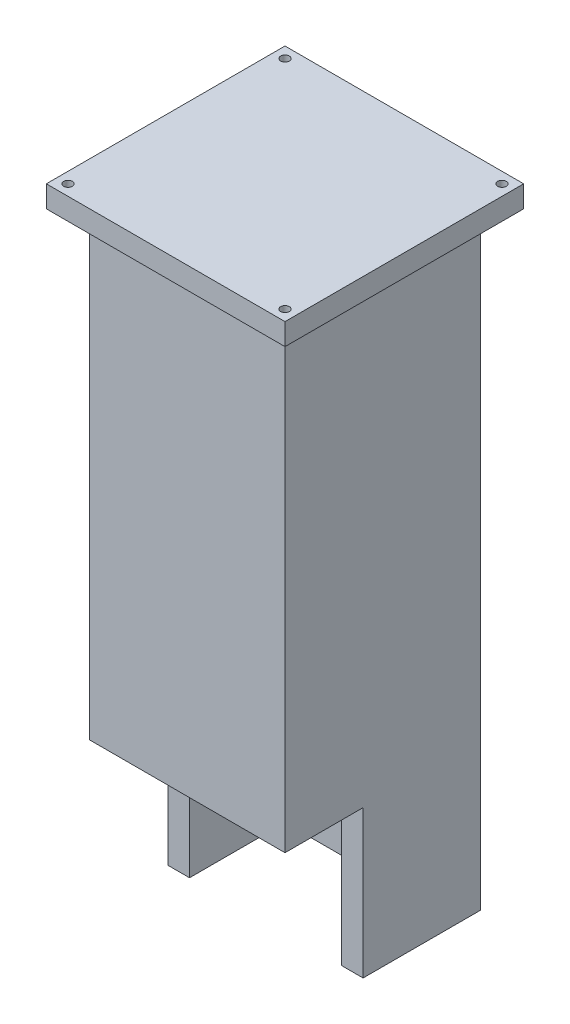
from build123d import *

# Parameters (mm, degrees)
CROQUIS1_W                 = 45
CROQUIS1_H                 = 45
SALIENTE_EXTRUIR1_DEPTH    = 300
CROQUIS4_W                 = 18
CROQUIS4_H                 = 34
CORTAR_EXTRUIR2_DEPTH      = 46
CROQUIS8_W                 = 35
CROQUIS8_H                 = 35
CORTAR_EXTRUIR3_DEPTH      = 301
CROQUIS9_W                 = 35
CROQUIS9_H                 = 21.174410022
CORTAR_EXTRUIR4_DEPTH      = 10
CROQUIS10_R                = 1
CORTAR_EXTRUIR5_DEPTH      = 10
CROQUIS11_W                = 45
CROQUIS11_H                = 26.387879272
CORTAR_EXTRUIR6_DEPTH      = 46
CROQUIS13_W                = 45
CROQUIS13_H                = 133.61212073
CORTAR_EXTRUIR9_DEPTH      = 23.5
CORTAR_EXTRUIR9_DEPTH_BACK = 23.5
CROQUIS14_W                = 55
CROQUIS14_H                = 55
CROQUIS14_R                = 1
SALIENTE_EXTRUIR3_DEPTH    = 5


with BuildPart() as part:
    # Croquis1 → Saliente-Extruir1 (new body)
    with BuildSketch(Plane(origin=(0, 0, 0), x_dir=(1, 0, 0), z_dir=(0, 1, 0))):
        Rectangle(CROQUIS1_W, CROQUIS1_H)
    extrude(amount=SALIENTE_EXTRUIR1_DEPTH)

    # Croquis4 → Cortar-Extruir2 (cut, through all)
    with BuildSketch(Plane.ZY.offset(22.5)):
        with Locations((13.5, 17)):
            Rectangle(CROQUIS4_W, CROQUIS4_H)
    extrude(amount=-CORTAR_EXTRUIR2_DEPTH, mode=Mode.SUBTRACT)

    # Croquis8 → Cortar-Extruir3 (cut, through all)
    with BuildSketch(Plane(origin=(0, 300, 0), x_dir=(1, 0, 0), z_dir=(0, 1, 0))):
        Rectangle(CROQUIS8_W, CROQUIS8_H)
    extrude(amount=-CORTAR_EXTRUIR3_DEPTH, mode=Mode.SUBTRACT)

    # Croquis9 → Cortar-Extruir4 (cut)
    with BuildSketch(Plane(origin=(0, 0, -22.5), x_dir=(-1, 0, 0), z_dir=(0, 0, -1))):
        with Locations((0, 260)):
            Rectangle(CROQUIS9_W, CROQUIS9_H)
    extrude(amount=-CORTAR_EXTRUIR4_DEPTH, mode=Mode.SUBTRACT)

    # Croquis10 → Cortar-Extruir5 (cut)
    with BuildSketch(Plane.XY.offset(22.5)):
        with Locations((0, 260)):
            Circle(CROQUIS10_R)
    extrude(amount=-CORTAR_EXTRUIR5_DEPTH, mode=Mode.SUBTRACT)

    # Croquis11 → Cortar-Extruir6 (cut, through all)
    with BuildSketch(Plane.XY.offset(22.5)):
        with Locations((0, 286.806060364)):
            Rectangle(CROQUIS11_W, CROQUIS11_H)
    extrude(amount=-CORTAR_EXTRUIR6_DEPTH, mode=Mode.SUBTRACT)

    # Croquis13 → Cortar-Extruir9 (cut, two sides)
    with BuildSketch(Plane(origin=(0, 0, 0), x_dir=(0, 0, -1), z_dir=(1, 0, 0))) as cortar_extruir9_sk:
        with Locations((0, 206.806060363)):
            Rectangle(CROQUIS13_W, CROQUIS13_H)
    extrude(amount=CORTAR_EXTRUIR9_DEPTH, mode=Mode.SUBTRACT)
    extrude(cortar_extruir9_sk.sketch, amount=-CORTAR_EXTRUIR9_DEPTH_BACK, mode=Mode.SUBTRACT)

    # Croquis14 → Saliente-Extruir3 (add)
    with BuildSketch(Plane(origin=(0, 139.999999998, 0), x_dir=(1, 0, 0), z_dir=(0, 1, 0))):
        Rectangle(CROQUIS14_W, CROQUIS14_H)
        with Locations((-25, 25)):
            Circle(CROQUIS14_R, mode=Mode.SUBTRACT)
        with Locations((25, -25)):
            Circle(CROQUIS14_R, mode=Mode.SUBTRACT)
        with Locations((25, 25)):
            Circle(CROQUIS14_R, mode=Mode.SUBTRACT)
        with Locations((-25, -25)):
            Circle(CROQUIS14_R, mode=Mode.SUBTRACT)
    extrude(amount=SALIENTE_EXTRUIR3_DEPTH)


solid = part.part
